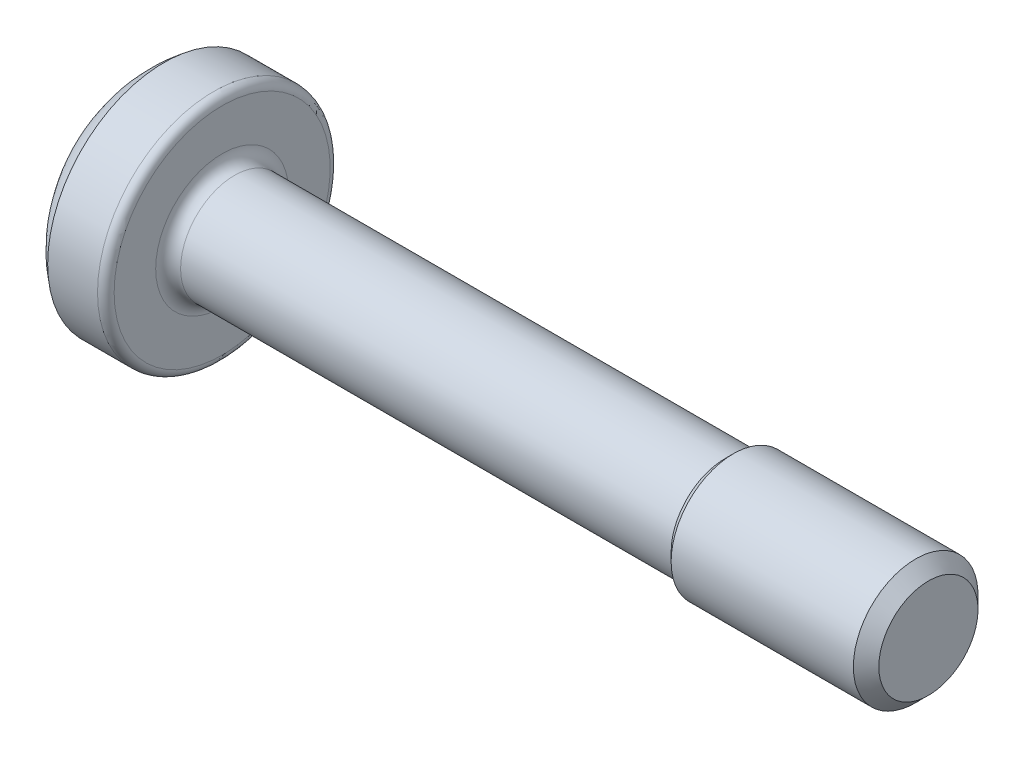
from build123d import *

# Parameters (mm, degrees)
CUT_EXTRUDE1_DEPTH = 2.1


with BuildPart() as part:
    # Sketch1 → Revolve1 (revolve)
    with BuildSketch(Plane.XY):
        with BuildLine():
            Line((-2.4, 0), (-2.4, 1.4))
            ThreePointArc((-2.4, 1.4), (-2.010193737, 2.178709812), (-1.4, 2.8))
            Line((-1.4, 2.8), (-0.2, 2.8))
            ThreePointArc((-0.2, 2.8), (-0.058578644, 2.741421356), (0, 2.6))
            Line((0, 2.6), (0, 1.6))
            ThreePointArc((0, 1.6), (0.087867966, 1.387867966), (0.3, 1.3))
            Line((0.3, 1.3), (12.1065, 1.3))
            Line((12.1065, 1.3), (12.3065, 1.5))
            Line((12.3065, 1.5), (16.6935, 1.5))
            Line((16.6935, 1.5), (17, 1.1935))
            Line((17, 1.1935), (17, 0))
            Line((17, 0), (-2.4, 0))
        make_face()
    revolve(axis=Axis((17, 0, 0), (-1, 0, 0)))

    # Sketch2 → Cut-Extrude1 (cut)
    with BuildSketch(Plane.ZY.offset(2.4)):
        with BuildLine():
            Line((0.38, -2.014472636), (0.38, -0.975538848))
            ThreePointArc((0.38, -0.975538848), (0.613182892, -0.826946318), (0.88968299, -0.828248869))
            ThreePointArc((0.88968299, -0.828248869), (1.212435563, -0.700000005), (1.162126064, -0.356363644))
            ThreePointArc((1.162126064, -0.356363644), (1.008436863, -6e-09), (1.162126056, 0.356363636))
            ThreePointArc((1.162126056, 0.356363636), (1.212435568, 0.699999995), (0.889683001, 0.828248872))
            ThreePointArc((0.889683001, 0.828248872), (0.613182897, 0.826946316), (0.38, 0.975538848))
            Line((0.38, 0.975538848), (0.38, 2.014472636))
            ThreePointArc((0.38, 2.014472636), (0, 2.05), (-0.38, 2.014472636))
            Line((-0.38, 2.014472636), (-0.38, 0.975538848))
            ThreePointArc((-0.38, 0.975538848), (-0.613182887, 0.826946319), (-0.889682981, 0.828248866))
            ThreePointArc((-0.889682981, 0.828248866), (-1.212435565, 0.700000001), (-1.162126051, 0.356363631))
            ThreePointArc((-1.162126051, 0.356363631), (-1.008436863, -7e-09), (-1.162126061, -0.356363641))
            ThreePointArc((-1.162126061, -0.356363641), (-1.212435561, -0.700000008), (-0.889682979, -0.828248866))
            ThreePointArc((-0.889682979, -0.828248866), (-0.613182886, -0.826946319), (-0.38, -0.975538848))
            Line((-0.38, -0.975538848), (-0.38, -2.014472636))
            ThreePointArc((-0.38, -2.014472636), (0, -2.05), (0.38, -2.014472636))
        make_face()
    extrude(amount=-CUT_EXTRUDE1_DEPTH, mode=Mode.SUBTRACT)

    # Sketch3 → Cut-Revolve1 (revolve, cut)
    with BuildSketch(Plane.XY):
        Polygon((-2.4, 0), (-2.4, 1.4), (-1, 0), align=None)
    revolve(axis=Axis((-1, 0, 0), (-1, 0, 0)), mode=Mode.SUBTRACT)


solid = part.part
